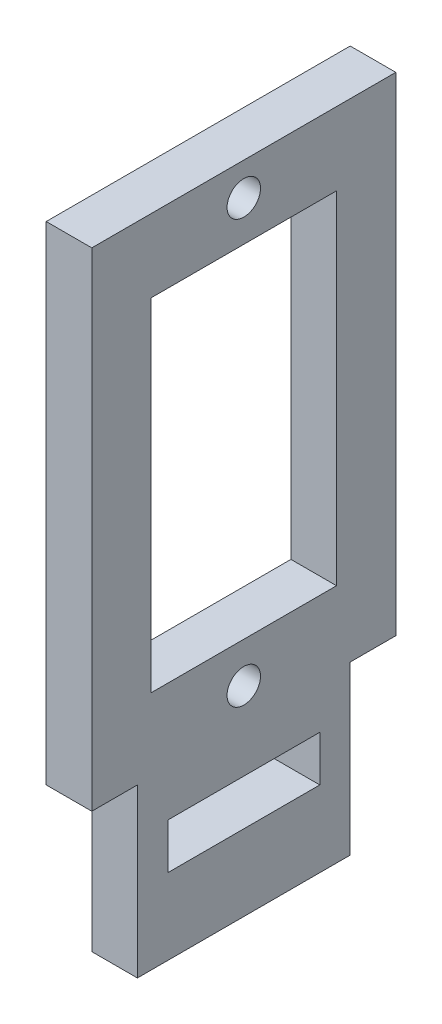
from build123d import *

# Parameters (mm, degrees)
SKETCH1_W           = 20
SKETCH1_H           = 43.1
SKETCH1_W_2         = 10
SKETCH1_H_2         = 3
BOSS_EXTRUDE1_DEPTH = 3
SKETCH2_R           = 1.1
SKETCH2_W           = 12.2
SKETCH2_H           = 22.5
SKETCH2_W_2         = 3
SKETCH2_H_2         = 11
CUT_EXTRUDE1_DEPTH  = 3


with BuildPart() as part:
    # Sketch1 → Boss-Extrude1 (new body)
    with BuildSketch(Plane(origin=(0, 0, 0), x_dir=(0, 0, -1), z_dir=(1, 0, 0))):
        with Locations((10, 21.55)):
            Rectangle(SKETCH1_W, SKETCH1_H)
        with Locations((10, 6.5)):
            Rectangle(SKETCH1_W_2, SKETCH1_H_2, mode=Mode.SUBTRACT)
    extrude(amount=BOSS_EXTRUDE1_DEPTH)

    # Sketch2 → Cut-Extrude1 (cut)
    with BuildSketch(Plane.ZY):
        with Locations((-10, 40.95)):
            Circle(SKETCH2_R)
        with Locations((-10, 13.15)):
            Circle(SKETCH2_R)
        with Locations((-10, 27.05)):
            Rectangle(SKETCH2_W, SKETCH2_H)
        with Locations((-18.5, 5.5)):
            Rectangle(SKETCH2_W_2, SKETCH2_H_2)
        with Locations((-1.5, 5.5)):
            Rectangle(SKETCH2_W_2, SKETCH2_H_2)
    extrude(amount=-CUT_EXTRUDE1_DEPTH, mode=Mode.SUBTRACT)


solid = part.part
